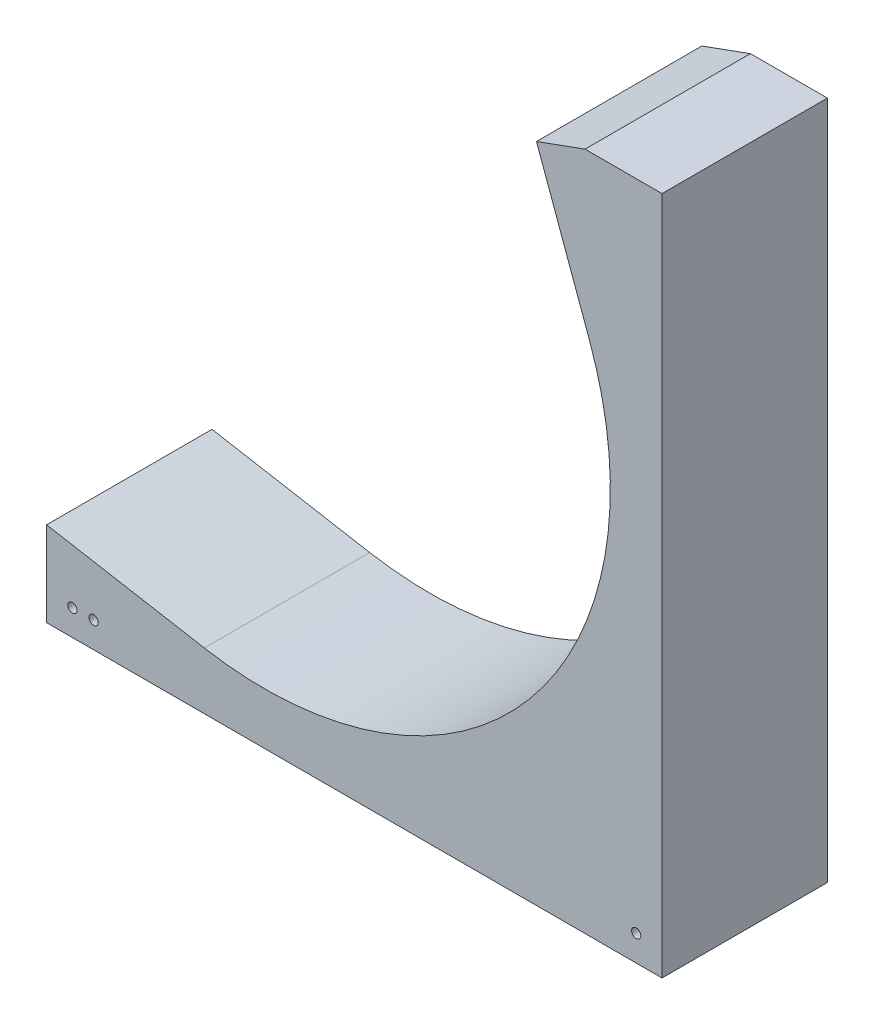
from build123d import *

# Parameters (mm, degrees)
BOSS_EXTRUDE1_DEPTH = 40.64
SKETCH6_R           = 1.1303
CUT_EXTRUDE1_DEPTH  = 158.779215984
SKETCH7_W           = 73.663303239
SKETCH7_H           = 73.66330324
CUT_EXTRUDE2_DEPTH  = 158.779215984
SKETCH8_R           = 1.1303
CUT_EXTRUDE3_DEPTH  = 145.040213208


with BuildPart() as part:
    # Sweep3: sweep along a path in Sketch2
    with BuildLine(Plane.XY) as sweep3_path:
        Line((-111.378641457, -46.568583299), (-11.322173751, -64.21123815))
        ThreePointArc((-11.322173751, -64.21123815), (49.947476571, -41.910909169), (61.269650322, 22.300328981))
        Line((61.269650322, 22.300328981), (48.238682861, 58.102617833))
    # 3DSketch1 → Sweep3 (sweep)
    with BuildSketch(Plane(origin=(-117.024291009, -78.586652965, -20.32), x_dir=(0.051794909001673446, 0.2937435257699459, 0.9544799780350292), z_dir=(0.984807753012208, -0.17364817766693055, 0))):
        Polygon((0, 0), (3.788092413, -12.121895721), (42.57815872, 0), (38.790066307, 12.121895721), align=None)
    sweep(path=sweep3_path.line)

    # Sketch5 → Boss-Extrude1 (add)
    with BuildSketch(Plane.XY.offset(20.32)):
        with BuildLine():
            Line((-16.967823303, -96.229307816), (-117.024291009, -78.586652965))
            Line((-117.024291009, -78.586652965), (-117.024291009, -97.7138))
            Line((-117.024291009, -97.7138), (-2e-08, -97.7138))
            ThreePointArc((-2e-08, -97.7138), (-8.516318826, -97.34196949), (-16.967823303, -96.229307816))
        make_face()
        with BuildLine():
            ThreePointArc((97.7138, 6e-08), (69.09409061, -69.094090581), (-2e-08, -97.7138))
            Line((-2e-08, -97.7138), (97.7138, -97.7138))
            Line((97.7138, -97.7138), (97.7138, 6e-08))
        make_face()
        with BuildLine():
            ThreePointArc((91.820936809, 33.420087881), (96.229307811, 16.967823332), (97.7138, 6e-08))
            Line((97.7138, 6e-08), (97.7138, 69.222376733))
            Line((97.7138, 69.222376733), (78.789969348, 69.222376733))
            Line((78.789969348, 69.222376733), (91.820936809, 33.420087881))
        make_face()
    extrude(amount=-BOSS_EXTRUDE1_DEPTH)

    # Sketch6 → Cut-Extrude1 (cut, through all)
    with BuildSketch(Plane.XY.offset(20.32)):
        with Locations((91.3638, -91.3638)):
            Circle(SKETCH6_R)
        with Locations((-41.9735, -91.3638)):
            Circle(SKETCH6_R)
    extrude(amount=-CUT_EXTRUDE1_DEPTH, mode=Mode.SUBTRACT)

    # Sketch7 → Cut-Extrude2 (cut, through all)
    with BuildSketch(Plane.XY.offset(20.32)):
        with Locations((-90.355942629, -60.88214838)):
            Rectangle(SKETCH7_W, SKETCH7_H)
    extrude(amount=-CUT_EXTRUDE2_DEPTH, mode=Mode.SUBTRACT)

    # Sketch8 → Cut-Extrude3 (cut, through all)
    with BuildSketch(Plane.XY.offset(20.32)):
        with Locations((-47.174291009, -91.3638)):
            Circle(SKETCH8_R)
    extrude(amount=-CUT_EXTRUDE3_DEPTH, mode=Mode.SUBTRACT)


solid = part.part
